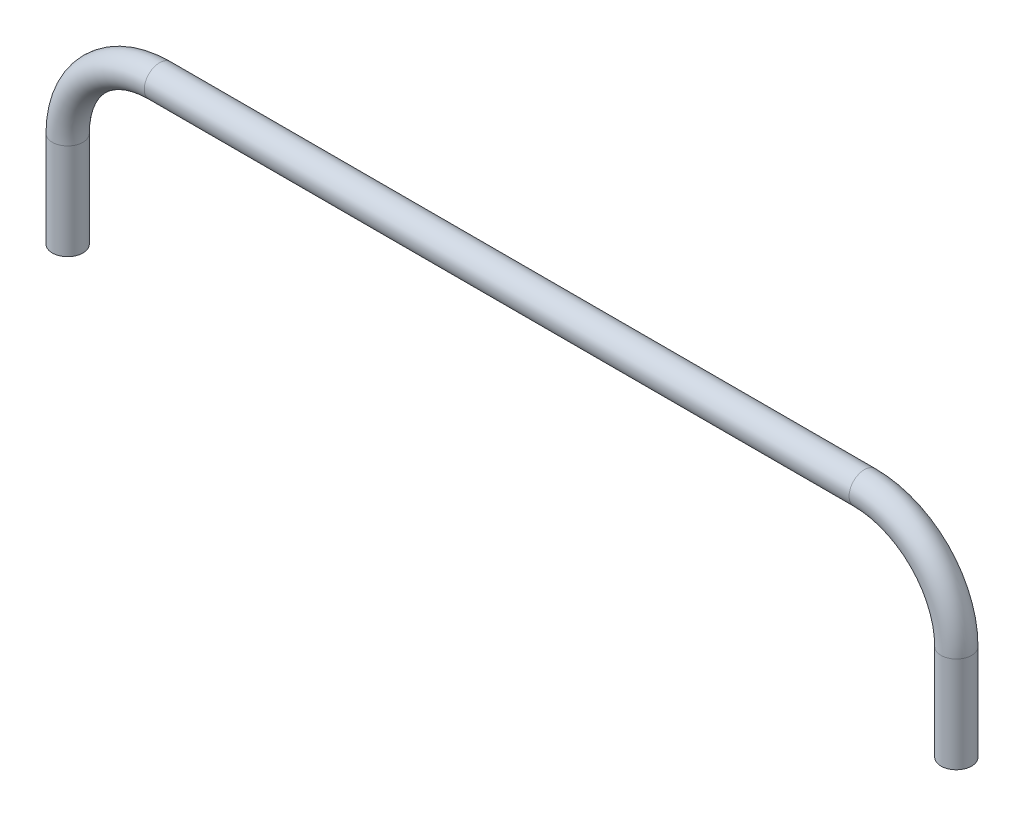
from build123d import *

# Parameters (mm, degrees)
SKETCH14_R   = 12.7
SKETCH14_R_2 = 8.73125


with BuildPart() as part:
    # Sweep2: sweep along a path in Sketch1
    with BuildLine(Plane.XY) as sweep2_path:
        Line((0, 0), (0, 79.502))
        ThreePointArc((0, 79.502), (22.318463274, 133.383536726), (76.2, 155.702))
        Line((76.2, 155.702), (660.4, 155.702))
        ThreePointArc((660.4, 155.702), (714.281536726, 133.383536726), (736.6, 79.502))
        Line((736.6, 79.502), (736.6, 0))
    # Sketch14 → Sweep2 (sweep)
    with BuildSketch(Plane(origin=(0, 0, 0), x_dir=(1, 0, 0), z_dir=(0, 1, 0))):
        Circle(SKETCH14_R)
        Circle(SKETCH14_R_2, mode=Mode.SUBTRACT)
    sweep(path=sweep2_path.line)


solid = part.part
